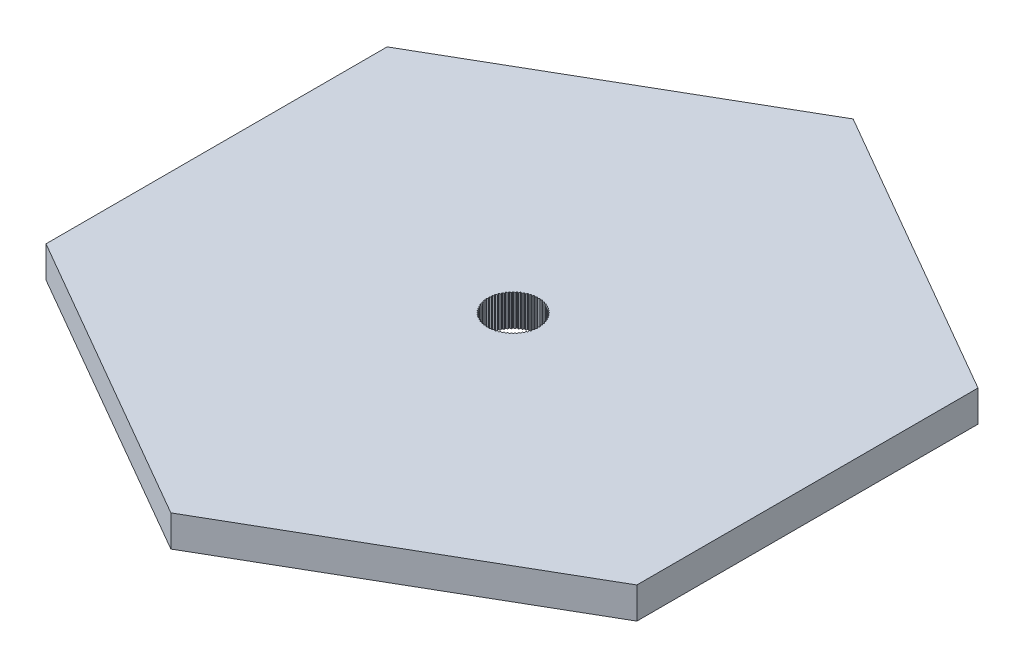
from build123d import *

# Parameters (mm, degrees)
BOSS_EXTRUDE1_DEPTH = 3
CUT_EXTRUDE1_DEPTH  = 10


with BuildPart() as part:
    # Sketch1 → Boss-Extrude1 (new body)
    with BuildSketch(Plane(origin=(0, 0, 0), x_dir=(1, 0, 0), z_dir=(0, 1, 0))):
        Polygon((0, -32.66572104), (28.289344254, -16.33286052), (28.289344254, 16.33286052), (0, 32.66572104), (-28.289344254, 16.33286052), (-28.289344254, -16.33286052), align=None)
    extrude(amount=BOSS_EXTRUDE1_DEPTH)

    # Sketch3 → Cut-Extrude1 (cut)
    with BuildSketch(Plane(origin=(0, 3, 0), x_dir=(1, 0, 0), z_dir=(0, 1, 0))):
        with BuildLine():
            Line((0.393496885, 2.699936231), (0.277218353, 2.62442407))
            Line((0.277218353, 2.62442407), (0.201706192, 2.740702601))
            ThreePointArc((0.201706192, 2.740702601), (0.171890319, 2.745613642), (0.142016144, 2.750156576))
            Line((0.142016144, 2.750156576), (0.034267768, 2.662903662))
            Line((0.034267768, 2.662903662), (-0.052985146, 2.770652038))
            ThreePointArc((-0.052985146, 2.770652038), (-0.083151028, 2.772419568), (-0.113336415, 2.773814914))
            Line((-0.113336415, 2.773814914), (-0.21137412, 2.675777208))
            Line((-0.21137412, 2.675777208), (-0.309411826, 2.773814914))
            ThreePointArc((-0.309411826, 2.773814914), (-0.339597213, 2.772419568), (-0.369763095, 2.770652038))
            Line((-0.369763095, 2.770652038), (-0.457016009, 2.662903662))
            Line((-0.457016009, 2.662903662), (-0.564764385, 2.750156576))
            ThreePointArc((-0.564764385, 2.750156576), (-0.59463856, 2.745613642), (-0.624454432, 2.740702601))
            Line((-0.624454432, 2.740702601), (-0.699966594, 2.62442407))
            Line((-0.699966594, 2.62442407), (-0.816245126, 2.699936231))
            ThreePointArc((-0.816245126, 2.699936231), (-0.845480781, 2.692295482), (-0.874619976, 2.684294737))
            Line((-0.874619976, 2.684294737), (-0.937564057, 2.560760021))
            Line((-0.937564057, 2.560760021), (-1.061098773, 2.623704103))
            ThreePointArc((-1.061098773, 2.623704103), (-1.089375597, 2.613049253), (-1.117518858, 2.602046461))
            Line((-1.117518858, 2.602046461), (-1.167205232, 2.472609033))
            Line((-1.167205232, 2.472609033), (-1.29664266, 2.522295407))
            ThreePointArc((-1.29664266, 2.522295407), (-1.323650845, 2.508743192), (-1.35048983, 2.494858903))
            Line((-1.35048983, 2.494858903), (-1.38637412, 2.360936907))
            Line((-1.38637412, 2.360936907), (-1.520296117, 2.396821198))
            ThreePointArc((-1.520296117, 2.396821198), (-1.545739756, 2.380520099), (-1.570980411, 2.363906432))
            Line((-1.570980411, 2.363906432), (-1.592669463, 2.226967145))
            Line((-1.592669463, 2.226967145), (-1.729608751, 2.248656197))
            ThreePointArc((-1.729608751, 2.248656197), (-1.753209079, 2.229784814), (-1.776574861, 2.210623791))
            Line((-1.776574861, 2.210623791), (-1.783831045, 2.072167548))
            Line((-1.783831045, 2.072167548), (-1.922287289, 2.079423732))
            ThreePointArc((-1.922287289, 2.079423732), (-1.943785734, 2.058188822), (-1.965020645, 2.036690376))
            Line((-1.965020645, 2.036690376), (-1.95776446, 1.898234133))
            Line((-1.95776446, 1.898234133), (-2.096220703, 1.890977949))
            ThreePointArc((-2.096220703, 1.890977949), (-2.115381726, 1.867612166), (-2.13425311, 1.844011838))
            Line((-2.13425311, 1.844011838), (-2.112564057, 1.707072551))
            Line((-2.112564057, 1.707072551), (-2.249503345, 1.685383498))
            ThreePointArc((-2.249503345, 1.685383498), (-2.266117012, 1.660142844), (-2.28241811, 1.634699204))
            Line((-2.28241811, 1.634699204), (-2.246533819, 1.500777208))
            Line((-2.246533819, 1.500777208), (-2.380455816, 1.464892917))
            ThreePointArc((-2.380455816, 1.464892917), (-2.394340105, 1.438053932), (-2.407892319, 1.411045747))
            Line((-2.407892319, 1.411045747), (-2.358205946, 1.281608319))
            Line((-2.358205946, 1.281608319), (-2.487643374, 1.231921946))
            ThreePointArc((-2.487643374, 1.231921946), (-2.498646165, 1.203778684), (-2.509301015, 1.175501861))
            Line((-2.509301015, 1.175501861), (-2.446356934, 1.051967145))
            Line((-2.446356934, 1.051967145), (-2.56989165, 0.989023063))
            ThreePointArc((-2.56989165, 0.989023063), (-2.577892395, 0.959883868), (-2.585533144, 0.930648213))
            Line((-2.585533144, 0.930648213), (-2.510020982, 0.814369681))
            Line((-2.510020982, 0.814369681), (-2.626299514, 0.73885752))
            ThreePointArc((-2.626299514, 0.73885752), (-2.631210555, 0.709041647), (-2.635753489, 0.679167472))
            Line((-2.635753489, 0.679167472), (-2.548500575, 0.571419097))
            Line((-2.548500575, 0.571419097), (-2.65624895, 0.484166183))
            ThreePointArc((-2.65624895, 0.484166183), (-2.658016481, 0.454000301), (-2.659411826, 0.423814914))
            Line((-2.659411826, 0.423814914), (-2.56137412, 0.325777208))
            Line((-2.56137412, 0.325777208), (-2.659411826, 0.227739502))
            ThreePointArc((-2.659411826, 0.227739502), (-2.658016481, 0.197554115), (-2.65624895, 0.167388233))
            Line((-2.65624895, 0.167388233), (-2.548500575, 0.080135319))
            Line((-2.548500575, 0.080135319), (-2.635753489, -0.027613056))
            ThreePointArc((-2.635753489, -0.027613056), (-2.631210555, -0.057487231), (-2.626299514, -0.087303104))
            Line((-2.626299514, -0.087303104), (-2.510020982, -0.162815265))
            Line((-2.510020982, -0.162815265), (-2.585533144, -0.279093797))
            ThreePointArc((-2.585533144, -0.279093797), (-2.577892395, -0.308329453), (-2.56989165, -0.337468647))
            Line((-2.56989165, -0.337468647), (-2.446356934, -0.400412729))
            Line((-2.446356934, -0.400412729), (-2.509301015, -0.523947445))
            ThreePointArc((-2.509301015, -0.523947445), (-2.498646165, -0.552224268), (-2.487643374, -0.58036753))
            Line((-2.487643374, -0.58036753), (-2.358205946, -0.630053903))
            Line((-2.358205946, -0.630053903), (-2.407892319, -0.759491331))
            ThreePointArc((-2.407892319, -0.759491331), (-2.394340105, -0.786499516), (-2.380455816, -0.813338501))
            Line((-2.380455816, -0.813338501), (-2.246533819, -0.849222792))
            Line((-2.246533819, -0.849222792), (-2.28241811, -0.983144788))
            ThreePointArc((-2.28241811, -0.983144788), (-2.266117012, -1.008588428), (-2.249503345, -1.033829083))
            Line((-2.249503345, -1.033829083), (-2.112564057, -1.055518135))
            Line((-2.112564057, -1.055518135), (-2.13425311, -1.192457422))
            ThreePointArc((-2.13425311, -1.192457422), (-2.115381726, -1.21605775), (-2.096220703, -1.239423533))
            Line((-2.096220703, -1.239423533), (-1.95776446, -1.246679717))
            Line((-1.95776446, -1.246679717), (-1.965020645, -1.38513596))
            ThreePointArc((-1.965020645, -1.38513596), (-1.943785734, -1.406634406), (-1.922287289, -1.427869316))
            Line((-1.922287289, -1.427869316), (-1.783831045, -1.420613132))
            Line((-1.783831045, -1.420613132), (-1.776574861, -1.559069375))
            ThreePointArc((-1.776574861, -1.559069375), (-1.753209079, -1.578230398), (-1.729608751, -1.597101781))
            Line((-1.729608751, -1.597101781), (-1.592669463, -1.575412729))
            Line((-1.592669463, -1.575412729), (-1.570980411, -1.712352016))
            ThreePointArc((-1.570980411, -1.712352016), (-1.545739756, -1.728965683), (-1.520296117, -1.745266782))
            Line((-1.520296117, -1.745266782), (-1.38637412, -1.709382491))
            Line((-1.38637412, -1.709382491), (-1.35048983, -1.843304487))
            ThreePointArc((-1.35048983, -1.843304487), (-1.323650845, -1.857188776), (-1.29664266, -1.870740991))
            Line((-1.29664266, -1.870740991), (-1.167205232, -1.821054617))
            Line((-1.167205232, -1.821054617), (-1.117518858, -1.950492045))
            ThreePointArc((-1.117518858, -1.950492045), (-1.089375597, -1.961494837), (-1.061098773, -1.972149687))
            Line((-1.061098773, -1.972149687), (-0.937564057, -1.909205605))
            Line((-0.937564057, -1.909205605), (-0.874619976, -2.032740321))
            ThreePointArc((-0.874619976, -2.032740321), (-0.845480781, -2.040741066), (-0.816245126, -2.048381815))
            Line((-0.816245126, -2.048381815), (-0.699966594, -1.972869654))
            Line((-0.699966594, -1.972869654), (-0.624454432, -2.089148185))
            ThreePointArc((-0.624454432, -2.089148185), (-0.59463856, -2.094059226), (-0.564764385, -2.09860216))
            Line((-0.564764385, -2.09860216), (-0.457016009, -2.011349246))
            Line((-0.457016009, -2.011349246), (-0.369763095, -2.119097622))
            ThreePointArc((-0.369763095, -2.119097622), (-0.339597213, -2.120865152), (-0.309411826, -2.122260498))
            Line((-0.309411826, -2.122260498), (-0.21137412, -2.024222792))
            Line((-0.21137412, -2.024222792), (-0.113336415, -2.122260498))
            ThreePointArc((-0.113336415, -2.122260498), (-0.083151028, -2.120865152), (-0.052985146, -2.119097622))
            Line((-0.052985146, -2.119097622), (0.034267768, -2.011349246))
            Line((0.034267768, -2.011349246), (0.142016144, -2.09860216))
            ThreePointArc((0.142016144, -2.09860216), (0.171890319, -2.094059226), (0.201706192, -2.089148185))
            Line((0.201706192, -2.089148185), (0.277218353, -1.972869654))
            Line((0.277218353, -1.972869654), (0.393496885, -2.048381815))
            ThreePointArc((0.393496885, -2.048381815), (0.42273254, -2.040741066), (0.451871735, -2.032740321))
            Line((0.451871735, -2.032740321), (0.514815816, -1.909205605))
            Line((0.514815816, -1.909205605), (0.638350532, -1.972149687))
            ThreePointArc((0.638350532, -1.972149687), (0.666627356, -1.961494837), (0.694770617, -1.950492045))
            Line((0.694770617, -1.950492045), (0.744456991, -1.821054617))
            Line((0.744456991, -1.821054617), (0.873894419, -1.870740991))
            ThreePointArc((0.873894419, -1.870740991), (0.900902604, -1.857188776), (0.927741589, -1.843304487))
            Line((0.927741589, -1.843304487), (0.96362588, -1.709382491))
            Line((0.96362588, -1.709382491), (1.097547876, -1.745266782))
            ThreePointArc((1.097547876, -1.745266782), (1.122991515, -1.728965683), (1.14823217, -1.712352016))
            Line((1.14823217, -1.712352016), (1.169921222, -1.575412729))
            Line((1.169921222, -1.575412729), (1.30686051, -1.597101781))
            ThreePointArc((1.30686051, -1.597101781), (1.330460838, -1.578230398), (1.35382662, -1.559069375))
            Line((1.35382662, -1.559069375), (1.361082804, -1.420613132))
            Line((1.361082804, -1.420613132), (1.499539048, -1.427869316))
            ThreePointArc((1.499539048, -1.427869316), (1.521037493, -1.406634406), (1.542272404, -1.38513596))
            Line((1.542272404, -1.38513596), (1.535016219, -1.246679717))
            Line((1.535016219, -1.246679717), (1.673472462, -1.239423533))
            ThreePointArc((1.673472462, -1.239423533), (1.692633485, -1.21605775), (1.711504869, -1.192457422))
            Line((1.711504869, -1.192457422), (1.689815816, -1.055518135))
            Line((1.689815816, -1.055518135), (1.826755104, -1.033829083))
            ThreePointArc((1.826755104, -1.033829083), (1.843368771, -1.008588428), (1.859669869, -0.983144788))
            Line((1.859669869, -0.983144788), (1.823785578, -0.849222792))
            Line((1.823785578, -0.849222792), (1.957707575, -0.813338501))
            ThreePointArc((1.957707575, -0.813338501), (1.971591864, -0.786499516), (1.985144078, -0.759491331))
            Line((1.985144078, -0.759491331), (1.935457705, -0.630053903))
            Line((1.935457705, -0.630053903), (2.064895133, -0.58036753))
            ThreePointArc((2.064895133, -0.58036753), (2.075897924, -0.552224268), (2.086552774, -0.523947445))
            Line((2.086552774, -0.523947445), (2.023608693, -0.400412729))
            Line((2.023608693, -0.400412729), (2.147143409, -0.337468647))
            ThreePointArc((2.147143409, -0.337468647), (2.155144154, -0.308329453), (2.162784903, -0.279093797))
            Line((2.162784903, -0.279093797), (2.087272741, -0.162815265))
            Line((2.087272741, -0.162815265), (2.203551273, -0.087303104))
            ThreePointArc((2.203551273, -0.087303104), (2.208462314, -0.057487231), (2.213005248, -0.027613056))
            Line((2.213005248, -0.027613056), (2.125752334, 0.080135319))
            Line((2.125752334, 0.080135319), (2.233500709, 0.167388233))
            ThreePointArc((2.233500709, 0.167388233), (2.23526824, 0.197554115), (2.236663585, 0.227739502))
            Line((2.236663585, 0.227739502), (2.13862588, 0.325777208))
            Line((2.13862588, 0.325777208), (2.236663585, 0.423814914))
            ThreePointArc((2.236663585, 0.423814914), (2.23526824, 0.454000301), (2.233500709, 0.484166183))
            Line((2.233500709, 0.484166183), (2.125752334, 0.571419097))
            Line((2.125752334, 0.571419097), (2.213005248, 0.679167472))
            ThreePointArc((2.213005248, 0.679167472), (2.208462314, 0.709041647), (2.203551273, 0.73885752))
            Line((2.203551273, 0.73885752), (2.087272741, 0.814369681))
            Line((2.087272741, 0.814369681), (2.162784903, 0.930648213))
            ThreePointArc((2.162784903, 0.930648213), (2.155144154, 0.959883868), (2.147143409, 0.989023063))
            Line((2.147143409, 0.989023063), (2.023608693, 1.051967145))
            Line((2.023608693, 1.051967145), (2.086552774, 1.175501861))
            ThreePointArc((2.086552774, 1.175501861), (2.075897924, 1.203778684), (2.064895133, 1.231921946))
            Line((2.064895133, 1.231921946), (1.935457705, 1.281608319))
            Line((1.935457705, 1.281608319), (1.985144078, 1.411045747))
            ThreePointArc((1.985144078, 1.411045747), (1.971591864, 1.438053932), (1.957707575, 1.464892917))
            Line((1.957707575, 1.464892917), (1.823785578, 1.500777208))
            Line((1.823785578, 1.500777208), (1.859669869, 1.634699204))
            ThreePointArc((1.859669869, 1.634699204), (1.843368771, 1.660142844), (1.826755104, 1.685383498))
            Line((1.826755104, 1.685383498), (1.689815816, 1.707072551))
            Line((1.689815816, 1.707072551), (1.711504869, 1.844011838))
            ThreePointArc((1.711504869, 1.844011838), (1.692633485, 1.867612166), (1.673472462, 1.890977949))
            Line((1.673472462, 1.890977949), (1.535016219, 1.898234133))
            Line((1.535016219, 1.898234133), (1.542272404, 2.036690376))
            ThreePointArc((1.542272404, 2.036690376), (1.521037493, 2.058188822), (1.499539048, 2.079423732))
            Line((1.499539048, 2.079423732), (1.361082804, 2.072167548))
            Line((1.361082804, 2.072167548), (1.35382662, 2.210623791))
            ThreePointArc((1.35382662, 2.210623791), (1.330460838, 2.229784814), (1.30686051, 2.248656197))
            Line((1.30686051, 2.248656197), (1.169921222, 2.226967145))
            Line((1.169921222, 2.226967145), (1.14823217, 2.363906432))
            ThreePointArc((1.14823217, 2.363906432), (1.122991515, 2.380520099), (1.097547876, 2.396821198))
            Line((1.097547876, 2.396821198), (0.96362588, 2.360936907))
            Line((0.96362588, 2.360936907), (0.927741589, 2.494858903))
            ThreePointArc((0.927741589, 2.494858903), (0.900902604, 2.508743192), (0.873894419, 2.522295407))
            Line((0.873894419, 2.522295407), (0.744456991, 2.472609033))
            Line((0.744456991, 2.472609033), (0.694770617, 2.602046461))
            ThreePointArc((0.694770617, 2.602046461), (0.666627356, 2.613049253), (0.638350532, 2.623704103))
            Line((0.638350532, 2.623704103), (0.514815816, 2.560760021))
            Line((0.514815816, 2.560760021), (0.451871735, 2.684294737))
            ThreePointArc((0.451871735, 2.684294737), (0.42273254, 2.692295482), (0.393496885, 2.699936231))
        make_face()
    extrude(amount=-CUT_EXTRUDE1_DEPTH, mode=Mode.SUBTRACT)


solid = part.part
